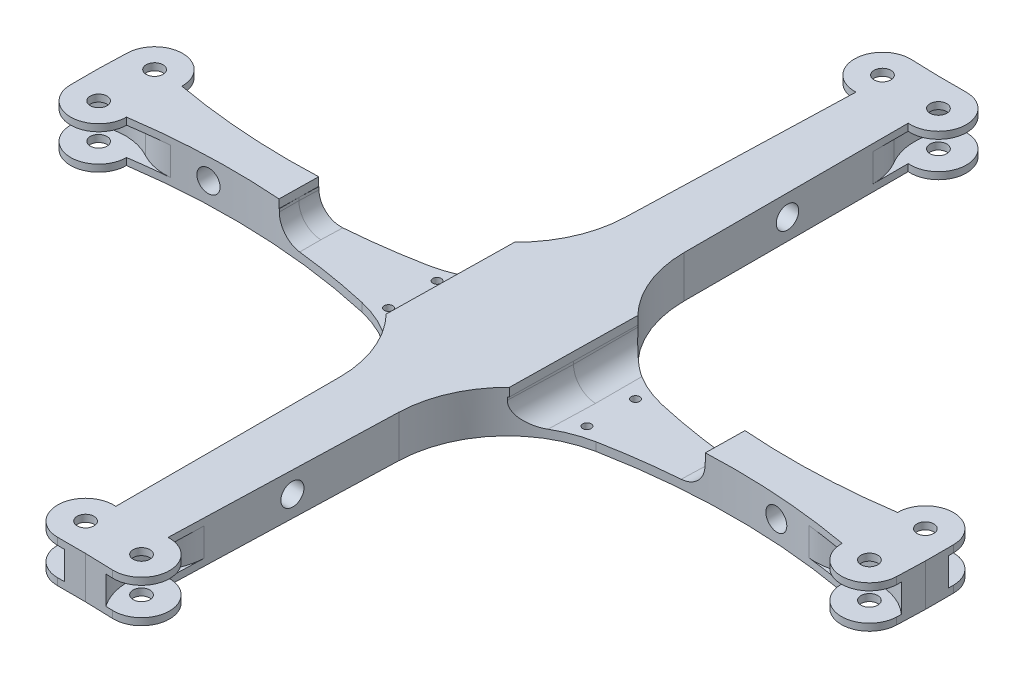
from build123d import *

# Parameters (mm, degrees)
SKETCH1_R           = 3
BOSS_EXTRUDE1_DEPTH = 7.5
SKETCH2_W           = 55
SKETCH2_H           = 9
CUT_EXTRUDE1_DEPTH  = 48.660195117
SKETCH3_W           = 20
SKETCH3_H           = 10
SKETCH4_W           = 20
SKETCH4_H           = 10
FILLET1_R           = 20
FILLET2_R           = 20
SKETCH6_R           = 1.5
CUT_EXTRUDE3_DEPTH  = 16.0000001
SKETCH7_R           = 4
CUT_EXTRUDE4_DEPTH  = 10
SKETCH8_R           = 4
CUT_EXTRUDE5_DEPTH  = 151.0000001
SKETCH9_W           = 55.006653609
SKETCH9_H           = 4.35409534
CUT_EXTRUDE6_DEPTH  = 153.296428766
FILLET3_R           = 8


with BuildPart() as part:
    # Sketch1 → Boss-Extrude1 (new body, symmetric)
    with BuildSketch(Plane(origin=(0, 0, 0), x_dir=(1, 0, 0), z_dir=(0, 1, 0))):
        with BuildLine():
            Line((-100.253548089, 84.689828669), (-100.253548089, 4.654657663))
            ThreePointArc((-100.253548089, 4.654657663), (-91.498999336, -20.31976478), (-69.067459271, -34.36219728))
            ThreePointArc((-69.067459271, -34.36219728), (-25.568113503, -40.037884103), (18.233349213, -37.621612765))
            ThreePointArc((18.233349213, -37.621612765), (28.252565995, -27.660213725), (38.233274783, -37.660195117))
            Line((38.233274783, -37.660195117), (38.233274783, -47.660195117))
            Line((38.233274783, -47.660195117), (-111.748581206, -45.327198326))
            Line((-111.748581206, -45.327198326), (-109.415584416, 104.654657663))
            Line((-109.415584416, 104.654657663), (-99.415584416, 104.654657663))
            ThreePointArc((-99.415584416, 104.654657663), (-89.424381036, 94.235306939), (-100.253548089, 84.689828669))
        make_face()
        with Locations((-99.415584416, 94.654657663)):
            Circle(SKETCH1_R, mode=Mode.SUBTRACT)
        with Locations((28.233274783, -37.660195117)):
            Circle(SKETCH1_R, mode=Mode.SUBTRACT)
    extrude(amount=BOSS_EXTRUDE1_DEPTH, both=True)

    # Sketch2 → Cut-Extrude1 (cut, through all)
    with BuildSketch(Plane.XY):
        with Locations((-61.915584416, 0)):
            Rectangle(SKETCH2_W, SKETCH2_H)
    extrude(amount=CUT_EXTRUDE1_DEPTH, mode=Mode.SUBTRACT)

    # Sketch3 → Cut-Revolve1 (revolve, cut)
    with BuildSketch(Plane(origin=(25.233274783, 0, 0), x_dir=(0, 0, -1), z_dir=(1, 0, 0))):
        with Locations((-34.160195117, 0)):
            Rectangle(SKETCH3_W, SKETCH3_H)
    revolve(axis=Axis((25.233274783, -5, 24.160195117), (0, 1, 0)), mode=Mode.SUBTRACT)

    # Sketch4 → Cut-Revolve2 (revolve, cut)
    with BuildSketch(Plane(origin=(0, 0, -92.654657663), x_dir=(-1, 0, 0), z_dir=(0, 0, -1))):
        with Locations((95.915584416, 0)):
            Rectangle(SKETCH4_W, SKETCH4_H)
    revolve(axis=Axis((-85.915584416, 5, -92.654657663), (0, -1, 0)), mode=Mode.SUBTRACT)

    # Fillet1
    fillet1_edges = [part.edges().sort_by_distance(p)[0] for p in [
        (-100.253548089, 0, -78.711100093),
    ]]
    fillet(fillet1_edges, radius=FILLET1_R)

    # Fillet2
    fillet2_edges = [part.edges().sort_by_distance(p)[0] for p in [
        (11.336587698, 0, 38.543591381),
    ]]
    fillet(fillet2_edges, radius=FILLET2_R)

    # Sketch6 → Cut-Extrude3 (cut, through all)
    with BuildSketch(Plane(origin=(0, 7.5, 0), x_dir=(1, 0, 0), z_dir=(0, 1, 0))):
        with Locations((-75.619784174, -37.345342337)):
            Circle(SKETCH6_R)
    extrude(amount=-CUT_EXTRUDE3_DEPTH, mode=Mode.SUBTRACT)

    # Sketch7 → Cut-Extrude4 (cut)
    with BuildSketch(Plane(origin=(-0.731935377, 0, 47.054083733), x_dir=(0.99987904, 0, 0.015553312), z_dir=(-0.015553312, 0, 0.99987904))):
        with Locations((-8, 0)):
            Circle(SKETCH7_R)
    extrude(amount=-CUT_EXTRUDE4_DEPTH, mode=Mode.SUBTRACT)

    # Sketch8 → Cut-Extrude5 (cut, through all)
    with BuildSketch(Plane(origin=(-111.016645829, 0, -1.726885407), x_dir=(-0.015553312, 0, 0.99987904), z_dir=(-0.99987904, 0, -0.015553312))):
        with Locations((-40, 0)):
            Circle(SKETCH8_R)
    extrude(amount=-CUT_EXTRUDE5_DEPTH, mode=Mode.SUBTRACT)

    # Sketch9 → Cut-Extrude6 (cut, through all)
    with BuildSketch(Plane(origin=(-0.731935377, 0, 47.054083733), x_dir=(0.99987904, 0, 0.015553312), z_dir=(-0.015553312, 0, 0.99987904))):
        with Locations((-61.191050713, 6.67704767)):
            Rectangle(SKETCH9_W, SKETCH9_H)
    extrude(amount=-CUT_EXTRUDE6_DEPTH, mode=Mode.SUBTRACT)

    # Fillet3
    fillet3_edges = [part.edges().sort_by_distance(p)[0] for p in [
        (-34.415584416, -4.5, 43.03618285),
        (-89.415584416, -4.5, 34.19915688),
    ]]
    fillet(fillet3_edges, radius=FILLET3_R)

    # Mirror1: part across plane


with BuildPart() as part_1:
    add(part.part)
    add(part.part.mirror(Plane(origin=(-111.748581206, 7.5, 45.327198326), x_dir=(-0.015553312, 0, 0.99987904), z_dir=(0.99987904, 0, 0.015553312))))

    # Mirror2: part across plane


with BuildPart() as part_2:
    add(part_1.part)
    add(part_1.part.mirror(Plane(origin=(-111.748581206, 7.5, 45.327198326), x_dir=(0.99987904, 0, 0.015553312), z_dir=(0.015553312, 0, -0.99987904))))


solid = part_2.part
